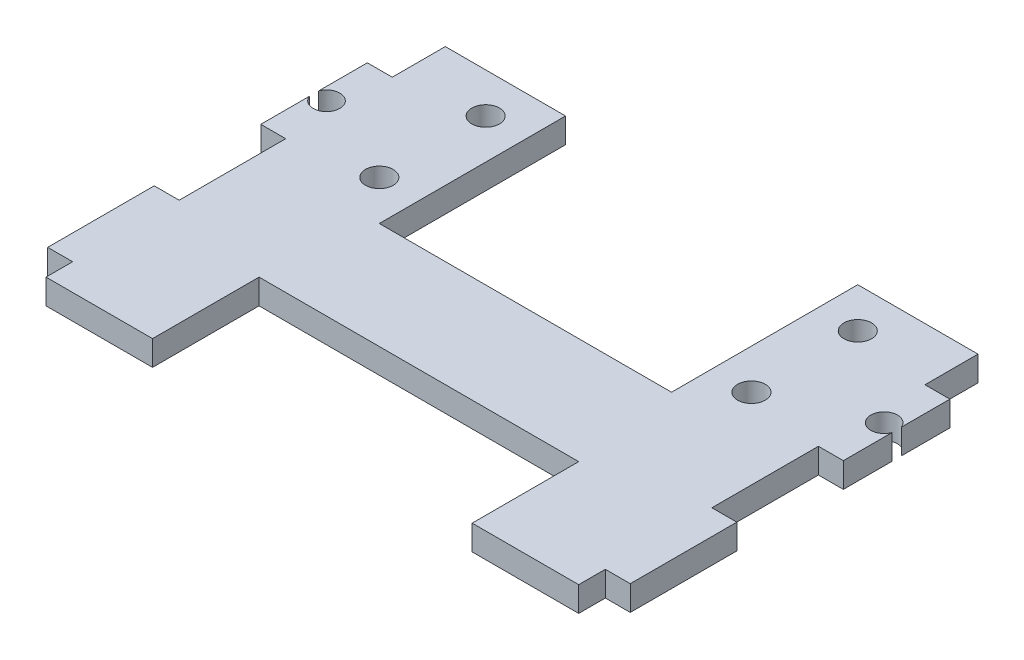
from build123d import *

# Parameters (mm, degrees)
SKETCH1_R           = 1.647641354
BOSS_EXTRUDE1_DEPTH = 2.9718
SKETCH2_R           = 1.5875
CUT_EXTRUDE1_DEPTH  = 3.9718


with BuildPart() as part:
    # Sketch1 → Boss-Extrude1 (new body)
    with BuildSketch(Plane(origin=(0, 0, 0), x_dir=(1, 0, 0), z_dir=(0, 1, 0))):
        Polygon((-17.417287452, 11.099582129), (-31.75, 11.099582129), (-31.75, 4.775417871), (-34.7218, 4.775417871), (-34.7218, -7.924582129), (-31.75, -7.924582129), (-31.75, -20.624582129), (-34.7218, -20.624582129), (-34.7218, -33.324582129), (-31.75, -33.324582129), (-31.75, -36.499582129), (-19.05, -36.499582129), (-19.05, -23.799582129), (19.05, -23.799582129), (19.05, -36.499582129), (31.75, -36.499582129), (31.75, -33.324582129), (34.7218, -33.324582129), (34.7218, -20.624582129), (31.75, -20.624582129), (31.75, -7.924582129), (34.7218, -7.924582129), (34.7218, 4.775417871), (31.75, 4.775417871), (31.75, 11.099582129), (17.417287452, 11.099582129), (17.417287452, -11.099582129), (-17.417287452, -11.099582129), align=None)
        with Locations((-22.179787452, -6.337082129)):
            Circle(SKETCH1_R, mode=Mode.SUBTRACT)
        with Locations((-22.179787452, 6.337082129)):
            Circle(SKETCH1_R, mode=Mode.SUBTRACT)
        with Locations((22.179787452, 6.337082129)):
            Circle(SKETCH1_R, mode=Mode.SUBTRACT)
        with Locations((22.179787452, -6.337082129)):
            Circle(SKETCH1_R, mode=Mode.SUBTRACT)
    extrude(amount=BOSS_EXTRUDE1_DEPTH)

    # Sketch2 → Cut-Extrude1 (cut, through all)
    with BuildSketch(Plane(origin=(0, 2.9718, 0), x_dir=(1, 0, 0), z_dir=(0, 1, 0))):
        with Locations((-33.2359, -1.574582129)):
            Circle(SKETCH2_R)
        with Locations((33.2359, -1.574582129)):
            Circle(SKETCH2_R)
    extrude(amount=-CUT_EXTRUDE1_DEPTH, mode=Mode.SUBTRACT)


solid = part.part
